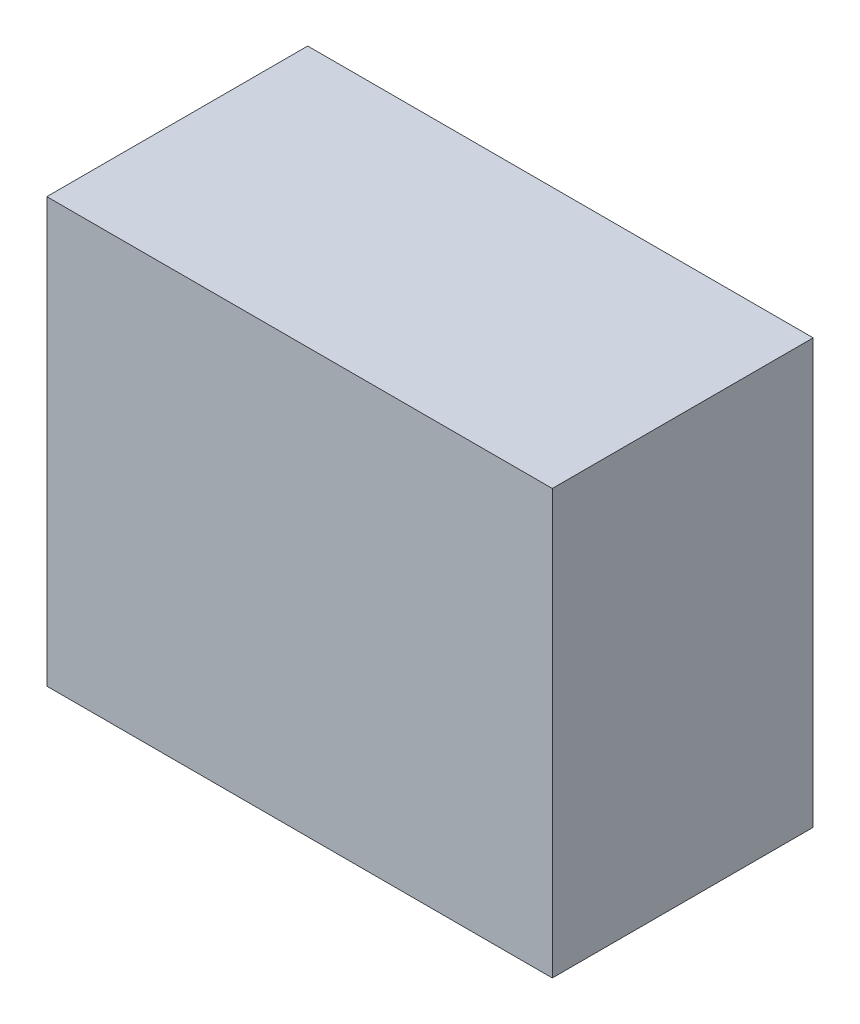
from build123d import *

# Parameters (mm, degrees)
SKETCH1_W           = 155
SKETCH1_H           = 130
BOSS_EXTRUDE1_DEPTH = 80


with BuildPart() as part:
    # Sketch1 → Boss-Extrude1 (new body)
    with BuildSketch(Plane.XY):
        with Locations((77.5, 65)):
            Rectangle(SKETCH1_W, SKETCH1_H)
    extrude(amount=BOSS_EXTRUDE1_DEPTH)


solid = part.part
